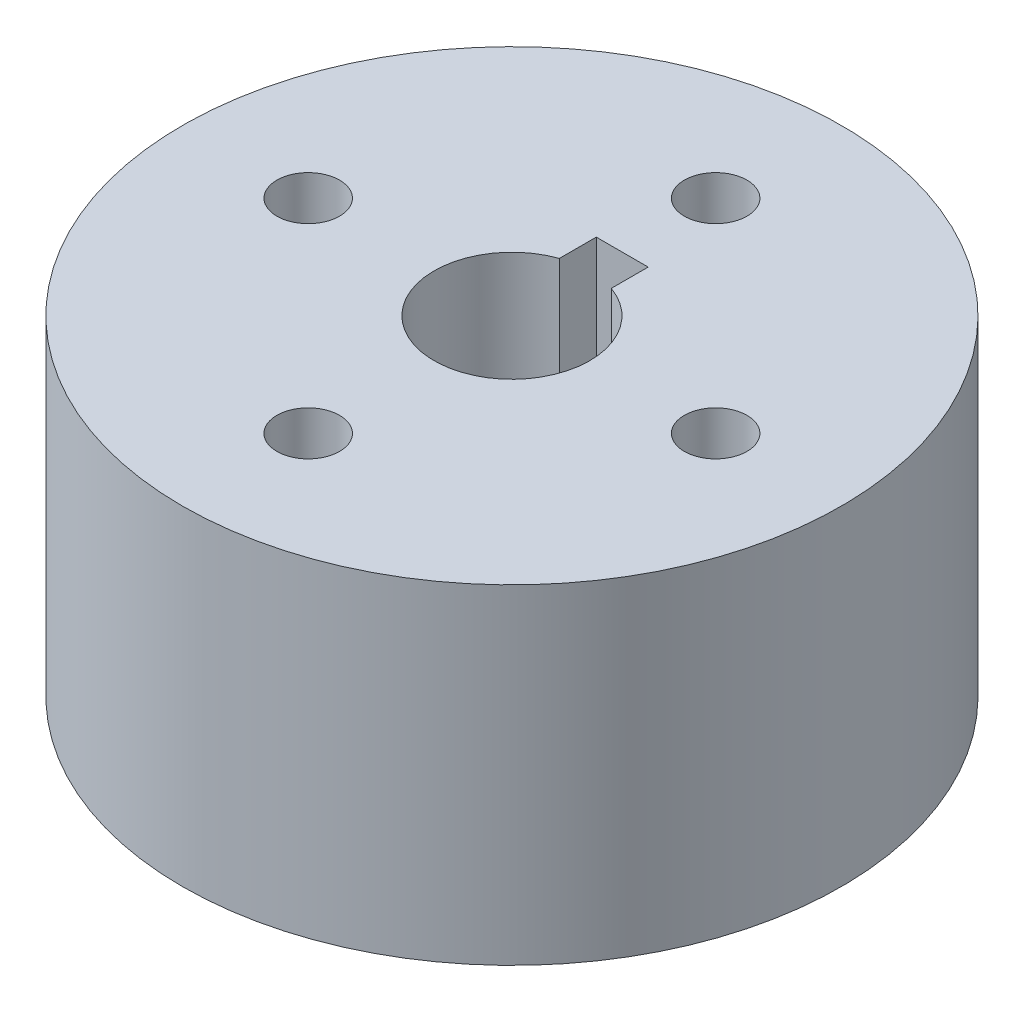
from build123d import *

# Parameters (mm, degrees)
SKETCH1_R           = 25.4
SKETCH1_R_2         = 6
BOSS_EXTRUDE1_DEPTH = 25.4
SKETCH2_W           = 4
SKETCH2_H           = 5
CUT_EXTRUDE1_DEPTH  = 16.825
SKETCH3_R           = 2.413
CUT_EXTRUDE2_DEPTH  = 26.4


with BuildPart() as part:
    # Sketch1 → Boss-Extrude1 (new body)
    with BuildSketch(Plane(origin=(0, 0, 0), x_dir=(1, 0, 0), z_dir=(0, 1, 0))):
        Circle(SKETCH1_R)
        Circle(SKETCH1_R_2, mode=Mode.SUBTRACT)
    extrude(amount=BOSS_EXTRUDE1_DEPTH)

    # Sketch2 → Cut-Extrude1 (cut)
    with BuildSketch(Plane(origin=(0, 25.4, 0), x_dir=(1, 0, 0), z_dir=(0, 1, 0))):
        with Locations((0, 6)):
            Rectangle(SKETCH2_W, SKETCH2_H)
    extrude(amount=-CUT_EXTRUDE1_DEPTH, mode=Mode.SUBTRACT)

    # Sketch3 → Cut-Extrude2 (cut, through all)
    with BuildSketch(Plane.XZ):
        with Locations((0, -15.7)):
            Circle(SKETCH3_R)
        with Locations((-15.7, 0)):
            Circle(SKETCH3_R)
        with Locations((0, 15.7)):
            Circle(SKETCH3_R)
        with Locations((15.7, 0)):
            Circle(SKETCH3_R)
    extrude(amount=-CUT_EXTRUDE2_DEPTH, mode=Mode.SUBTRACT)


solid = part.part
